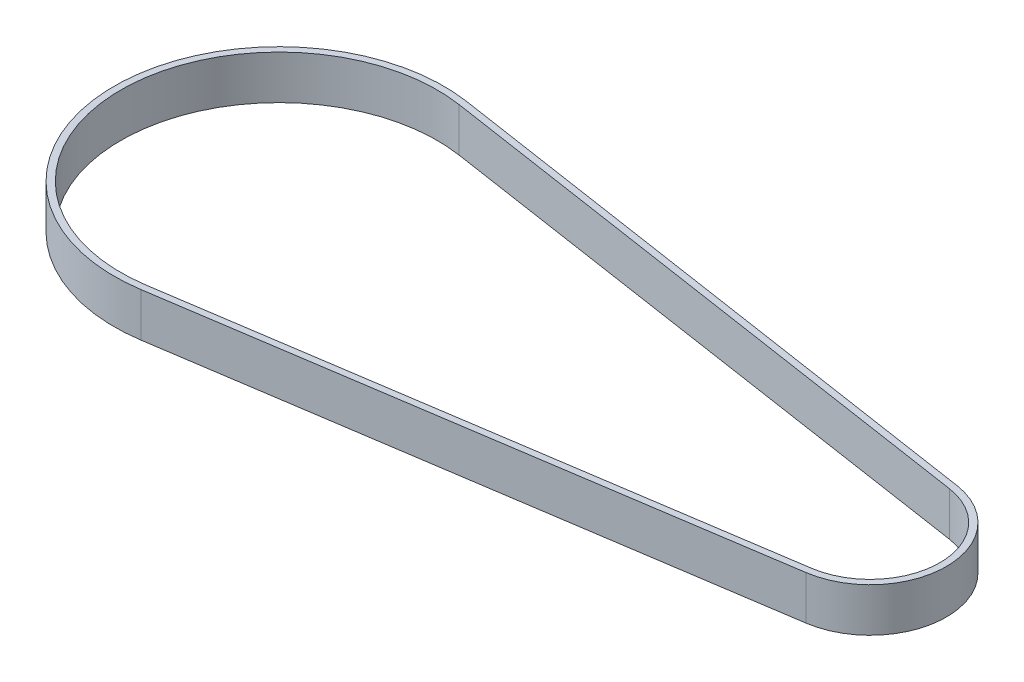
from build123d import *

# Parameters (mm, degrees)
BOSS_EXTRUDE1_DEPTH = 10


with BuildPart() as part:
    # Sketch1 → Boss-Extrude1 (new body)
    with BuildSketch(Plane(origin=(0, 0, 0), x_dir=(1, 0, 0), z_dir=(0, 1, 0))):
        with BuildLine():
            Line((-68.354812336, 37.201000274), (63.619675812, 17.218748698))
            ThreePointArc((63.619675812, 17.218748698), (78.427585812, 0), (63.619675812, -17.218748698))
            Line((63.619675812, -17.218748698), (-68.354812336, -37.201000274))
            ThreePointArc((-68.354812336, -37.201000274), (-111.612414188, 0), (-68.354812336, 37.201000274))
        make_face()
        with BuildLine():
            Line((-68.579367891, 35.717903917), (63.395120257, 15.735652342))
            ThreePointArc((63.395120257, 15.735652342), (76.927585812, 0), (63.395120257, -15.735652342))
            Line((63.395120257, -15.735652342), (-68.579367891, -35.717903917))
            ThreePointArc((-68.579367891, -35.717903917), (-110.112414188, 0), (-68.579367891, 35.717903917))
        make_face(mode=Mode.SUBTRACT)
    extrude(amount=BOSS_EXTRUDE1_DEPTH)


solid = part.part
